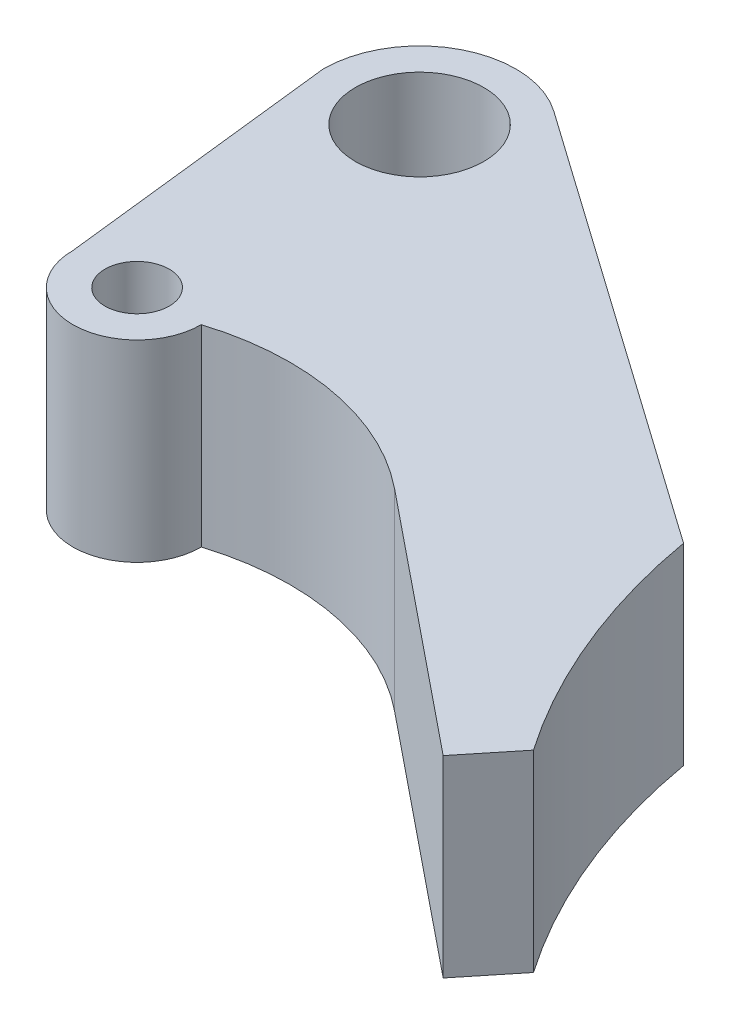
from build123d import *

# Parameters (mm, degrees)
SKETCH1_R           = 10
SKETCH1_R_2         = 5
BOSS_EXTRUDE1_DEPTH = 30


with BuildPart() as part:
    # Sketch1 → Boss-Extrude1 (new body)
    with BuildSketch(Plane(origin=(0, 0, 0), x_dir=(1, 0, 0), z_dir=(0, 1, 0))):
        with BuildLine():
            Line((-15, 24.031639244), (-10, -19.968360756))
            ThreePointArc((-10, -19.968360756), (0, -29.968360756), (10, -19.968360756))
            ThreePointArc((10, -19.968360756), (29.477373415, -18.829083409), (47.176676653, -27.038875908))
            Line((47.176676653, -27.038875908), (86.964311464, -59.258267297))
            Line((86.964311464, -59.258267297), (93.257515375, -51.486807682))
            ThreePointArc((93.257515375, -51.486807682), (83.004155911, -32.566658766), (77.036161898, -11.890913004))
            Line((77.036161898, -11.890913004), (8.638834838, 36.294205559))
            ThreePointArc((8.638834838, 36.294205559), (-6.907151274, 37.346715709), (-15, 24.031639244))
        make_face()
        with Locations((0, 24.031639244)):
            Circle(SKETCH1_R, mode=Mode.SUBTRACT)
        with Locations((0, -19.968360756)):
            Circle(SKETCH1_R_2, mode=Mode.SUBTRACT)
    extrude(amount=BOSS_EXTRUDE1_DEPTH)


solid = part.part
